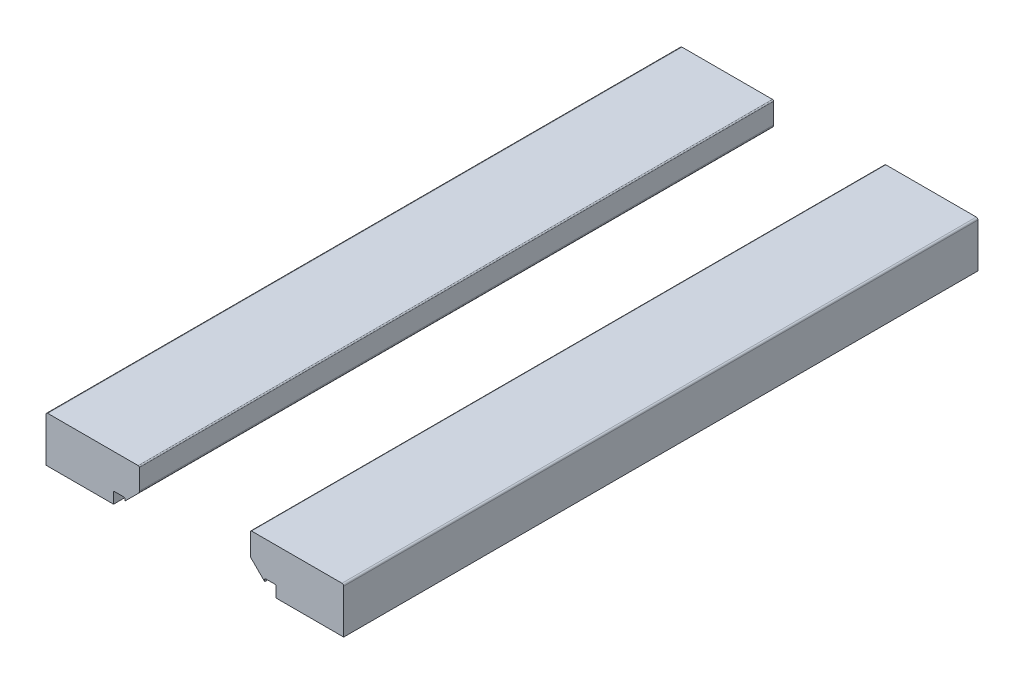
from build123d import *

# Parameters (mm, degrees)
RETAINERS_DEPTH   = 27.7
RETAINERS_2_DEPTH = 27.7


with BuildPart() as part:
    # Retainer Profile → Retainers (new body, symmetric)
    with BuildSketch(Plane.XY):
        with BuildLine():
            Line((13, 8.15), (13, 4.3))
            Line((13, 4.3), (7.1, 4.3))
            Line((7.1, 4.3), (7.1, 5.2))
            ThreePointArc((7.1, 5.2), (7.070710678, 5.270710678), (7, 5.3))
            Line((7, 5.3), (6.2, 5.3))
            ThreePointArc((6.2, 5.3), (6.129289322, 5.270710678), (6.1, 5.2))
            Line((6.1, 5.2), (6.1, 5.041421356))
            Line((6.1, 5.041421356), (4.937867966, 6.203553391))
            ThreePointArc((4.937867966, 6.203553391), (4.87283614, 6.300880395), (4.85, 6.415685425))
            Line((4.85, 6.415685425), (4.85, 8.2))
            ThreePointArc((4.85, 8.2), (4.879289322, 8.270710678), (4.95, 8.3))
            Line((4.95, 8.3), (12.85, 8.3))
            ThreePointArc((12.85, 8.3), (12.956066017, 8.256066017), (13, 8.15))
        make_face()
    extrude(amount=RETAINERS_DEPTH, both=True)


with BuildPart() as body_2:
    # Retainer Profile → Retainers 2 (new body, symmetric)
    with BuildSketch(Plane.XY):
        with BuildLine():
            Line((-4.937867966, 6.203553391), (-6.1, 5.041421356))
            Line((-6.1, 5.041421356), (-6.1, 5.2))
            ThreePointArc((-6.1, 5.2), (-6.129289322, 5.270710678), (-6.2, 5.3))
            Line((-6.2, 5.3), (-7, 5.3))
            ThreePointArc((-7, 5.3), (-7.070710678, 5.270710678), (-7.1, 5.2))
            Line((-7.1, 5.2), (-7.1, 4.3))
            Line((-7.1, 4.3), (-13, 4.3))
            Line((-13, 4.3), (-13, 8.15))
            ThreePointArc((-13, 8.15), (-12.956066017, 8.256066017), (-12.85, 8.3))
            Line((-12.85, 8.3), (-4.95, 8.3))
            ThreePointArc((-4.95, 8.3), (-4.879289322, 8.270710678), (-4.85, 8.2))
            Line((-4.85, 8.2), (-4.85, 6.415685425))
            ThreePointArc((-4.85, 6.415685425), (-4.87283614, 6.300880395), (-4.937867966, 6.203553391))
        make_face()
    extrude(amount=RETAINERS_2_DEPTH, both=True)


solid = Compound([part.part, body_2.part])
